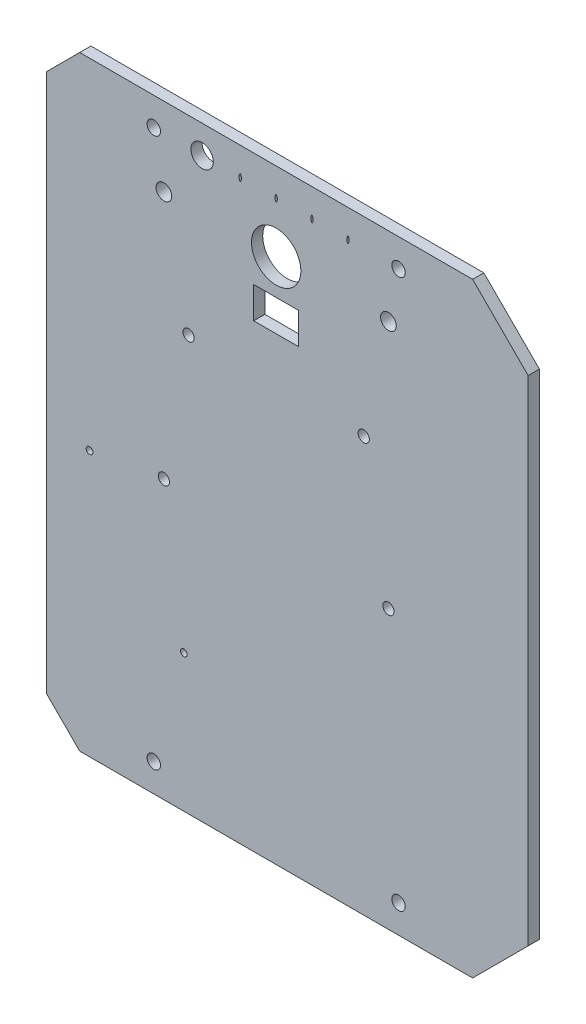
from build123d import *

# Parameters (mm, degrees)
BASE_DEPTH               = 5
ESQUISSE8_R              = 5
ENL_V_MAT_EXTRU_7_DEPTH  = 10
ESQUISSE4_R              = 11
ESQUISSE4_R_2            = 3.5
ESQUISSE4_RX             = 1.5
ESQUISSE4_RY             = 0.5
ESQUISSE4_W              = 20
ESQUISSE4_H              = 14
ENL_V_MAT_EXTRU_8_DEPTH  = 10
ESQUISSE2_R              = 3
ESQUISSE2_R_2            = 2.5
ENL_V_MAT_EXTRU_9_DEPTH  = 10
ESQUISSE11_R             = 1.5
ENL_V_MAT_EXTRU_11_DEPTH = 5


with BuildPart() as part:
    # Esquisse1 → Base (new body)
    with BuildSketch(Plane.XY):
        Polygon((0, 0), (-175, 0), (-199.748737342, 24.748737342), (-199.748737342, 244.748737342), (-175, 269.497474683), (0, 269.497474683), (24.748737342, 244.748737342), (24.748737342, 24.748737342), align=None)
    extrude(amount=BASE_DEPTH)

    # Esquisse8 → Enlèv. mat.-Extru.7 (cut)
    with BuildSketch(Plane.XY.offset(5)):
        with Locations((-120.5, 256.997474683)):
            Circle(ESQUISSE8_R)
    extrude(amount=-ENL_V_MAT_EXTRU_7_DEPTH, mode=Mode.SUBTRACT)

    # Esquisse4 → Enlèv. mat.-Extru.8 (cut)
    with BuildSketch(Plane.XY.offset(5)):
        with Locations((-87.5, 234.497474683)):
            Circle(ESQUISSE4_R)
        with Locations((-137.5, 234.497474683)):
            Circle(ESQUISSE4_R_2)
        with Locations((-37.5, 234.497474683)):
            Circle(ESQUISSE4_R_2)
        with Locations(Location((-103.5, 256.997474683), (0, 0, -90))):
            Ellipse(ESQUISSE4_RX, ESQUISSE4_RY)
        with Locations(Location((-87.5, 256.997474683), (0, 0, -90))):
            Ellipse(ESQUISSE4_RX, ESQUISSE4_RY)
        with Locations(Location((-71.5, 256.997474683), (0, 0, -90))):
            Ellipse(ESQUISSE4_RX, ESQUISSE4_RY)
        with Locations(Location((-55.5, 256.997474683), (0, 0, -90))):
            Ellipse(ESQUISSE4_RX, ESQUISSE4_RY)
        with Locations((-87.5, 211.748737342)):
            Rectangle(ESQUISSE4_W, ESQUISSE4_H)
    extrude(amount=-ENL_V_MAT_EXTRU_8_DEPTH, mode=Mode.SUBTRACT)

    # Esquisse2 → Enlèv. mat.-Extru.9 (cut)
    with BuildSketch(Plane.XY.offset(5)):
        with Locations((-141.998737342, 12.5)):
            Circle(ESQUISSE2_R)
        with Locations((-141.998737342, 256.997474683)):
            Circle(ESQUISSE2_R)
        with Locations((-33.001262658, 12.5)):
            Circle(ESQUISSE2_R)
        with Locations((-33.001262658, 256.997474683)):
            Circle(ESQUISSE2_R)
        with Locations((-137.5, 123.748737342)):
            Circle(ESQUISSE2_R_2)
        with Locations((-126.5, 184.748737342)):
            Circle(ESQUISSE2_R_2)
        with Locations((-37.5, 123.748737342)):
            Circle(ESQUISSE2_R_2)
        with Locations((-48.5, 184.748737342)):
            Circle(ESQUISSE2_R_2)
    extrude(amount=-ENL_V_MAT_EXTRU_9_DEPTH, mode=Mode.SUBTRACT)

    # Esquisse11 → Enlèv. mat.-Extru.11 (cut)
    with BuildSketch(Plane.XY.offset(5)):
        with Locations((-170.614939475, 118.152371839)):
            Circle(ESQUISSE11_R)
        with Locations((-128.614939475, 61.152371839)):
            Circle(ESQUISSE11_R)
        Polygon((-189.748737342, -12.261016229), (-189.748737342, 134.748737342), (-189.748737342, 274.920827955), (-199.748737342, 274.920827955), (-199.748737342, -12.261016229), align=None)
    extrude(amount=-ENL_V_MAT_EXTRU_11_DEPTH, mode=Mode.SUBTRACT)


solid = part.part
